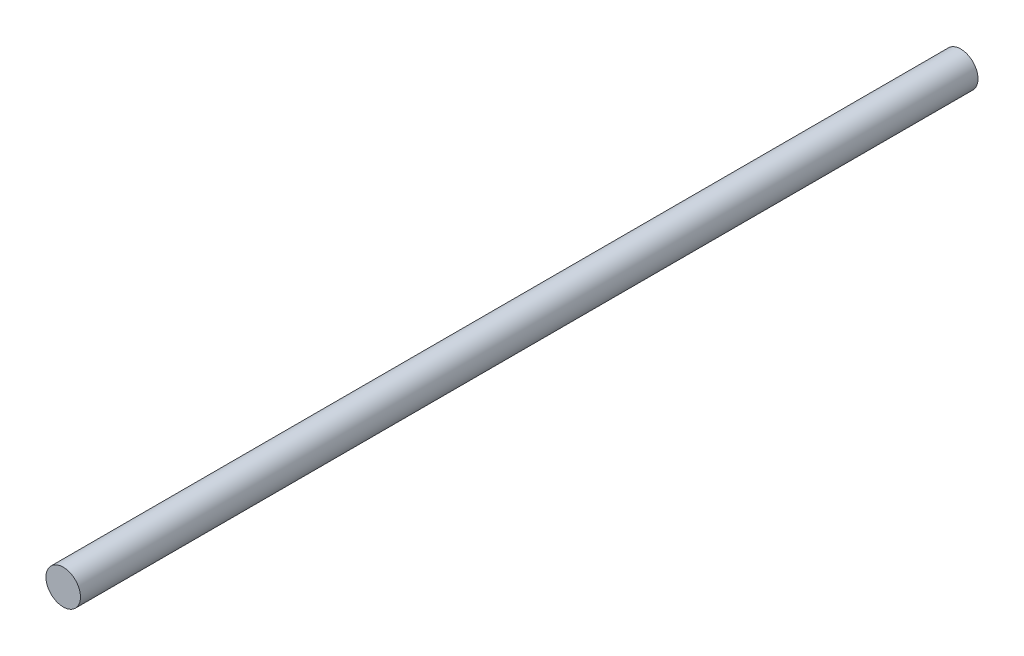
from build123d import *

# Parameters (mm, degrees)
SKETCH1_R           = 3.175
BOSS_EXTRUDE1_DEPTH = 165.1


with BuildPart() as part:
    # Sketch1 → Boss-Extrude1 (new body)
    with BuildSketch(Plane.XY):
        Circle(SKETCH1_R)
    extrude(amount=BOSS_EXTRUDE1_DEPTH)


solid = part.part
